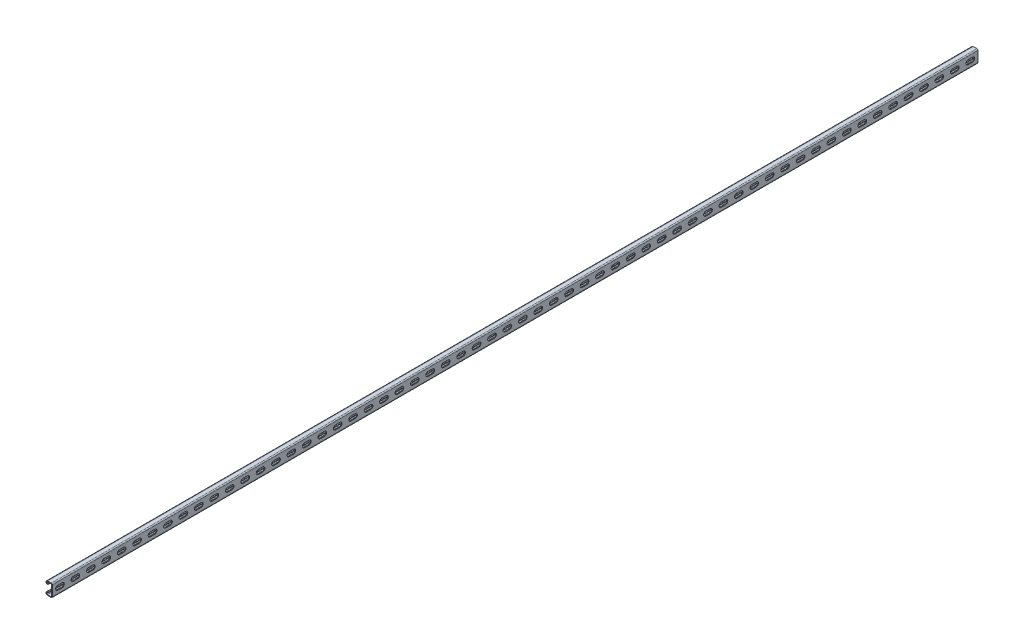
from build123d import *

# Parameters (mm, degrees)
BOSS_EXTRUDE1_DEPTH = 3048
CUT_EXTRUDE1_DEPTH  = 2.032
LPATTERN1_COUNT     = 60
LPATTERN1_PITCH     = 50.8


with BuildPart() as part:
    # Sketch1 → Boss-Extrude1 (new body)
    with BuildSketch(Plane.XY):
        with BuildLine():
            Line((-15.58925, 20.6375), (-3.46075, 20.6375))
            ThreePointArc((-3.46075, 20.6375), (-1.013630207, 19.623869793), (0, 17.17675))
            Line((0, 17.17675), (0, -17.17675))
            ThreePointArc((0, -17.17675), (-1.013630207, -19.623869793), (-3.46075, -20.6375))
            Line((-3.46075, -20.6375), (-15.58925, -20.6375))
            ThreePointArc((-15.58925, -20.6375), (-19.158901808, -19.158901808), (-20.6375, -15.58925))
            Line((-20.6375, -15.58925), (-20.6375, -14.57325))
            ThreePointArc((-20.6375, -14.57325), (-19.623869793, -12.126130207), (-17.17675, -11.1125))
            Line((-17.17675, -11.1125), (-14.5161, -11.1125))
            ThreePointArc((-14.5161, -11.1125), (-13.5001, -12.1285), (-14.5161, -13.1445))
            Line((-14.5161, -13.1445), (-17.17675, -13.1445))
            ThreePointArc((-17.17675, -13.1445), (-18.187028814, -13.562971186), (-18.6055, -14.57325))
            Line((-18.6055, -14.57325), (-18.6055, -15.58925))
            ThreePointArc((-18.6055, -15.58925), (-17.722060829, -17.722060829), (-15.58925, -18.6055))
            Line((-15.58925, -18.6055), (-3.46075, -18.6055))
            ThreePointArc((-3.46075, -18.6055), (-2.450471186, -18.187028814), (-2.032, -17.17675))
            Line((-2.032, -17.17675), (-2.032, 17.17675))
            ThreePointArc((-2.032, 17.17675), (-2.450471186, 18.187028814), (-3.46075, 18.6055))
            Line((-3.46075, 18.6055), (-15.58925, 18.6055))
            ThreePointArc((-15.58925, 18.6055), (-17.722060829, 17.722060829), (-18.6055, 15.58925))
            Line((-18.6055, 15.58925), (-18.6055, 14.57325))
            ThreePointArc((-18.6055, 14.57325), (-18.187028814, 13.562971186), (-17.17675, 13.1445))
            Line((-17.17675, 13.1445), (-14.5161, 13.1445))
            ThreePointArc((-14.5161, 13.1445), (-13.5001, 12.1285), (-14.5161, 11.1125))
            Line((-14.5161, 11.1125), (-17.17675, 11.1125))
            ThreePointArc((-17.17675, 11.1125), (-19.623869793, 12.126130207), (-20.6375, 14.57325))
            Line((-20.6375, 14.57325), (-20.6375, 15.58925))
            ThreePointArc((-20.6375, 15.58925), (-19.158901808, 19.158901808), (-15.58925, 20.6375))
        make_face()
    extrude(amount=-BOSS_EXTRUDE1_DEPTH)

    # Sketch2 → Cut-Extrude1 (cut)
    with BuildSketch(Plane(origin=(0, 0, 0), x_dir=(0, 0, -1), z_dir=(1, 0, 0))):
        with BuildLine():
            Line((18.25625, 7.14375), (32.54375, 7.14375))
            ThreePointArc((32.54375, 7.14375), (39.6875, 0), (32.54375, -7.14375))
            Line((32.54375, -7.14375), (18.25625, -7.14375))
            ThreePointArc((18.25625, -7.14375), (11.1125, 0), (18.25625, 7.14375))
        make_face()
    cut_extrude1 = extrude(amount=-CUT_EXTRUDE1_DEPTH, mode=Mode.SUBTRACT)

    # LPattern1: Cut-Extrude1 ×60
    with Locations(*[(0, 0, -i * LPATTERN1_PITCH) for i in range(1, LPATTERN1_COUNT)]):
        add(cut_extrude1, mode=Mode.SUBTRACT)


solid = part.part
